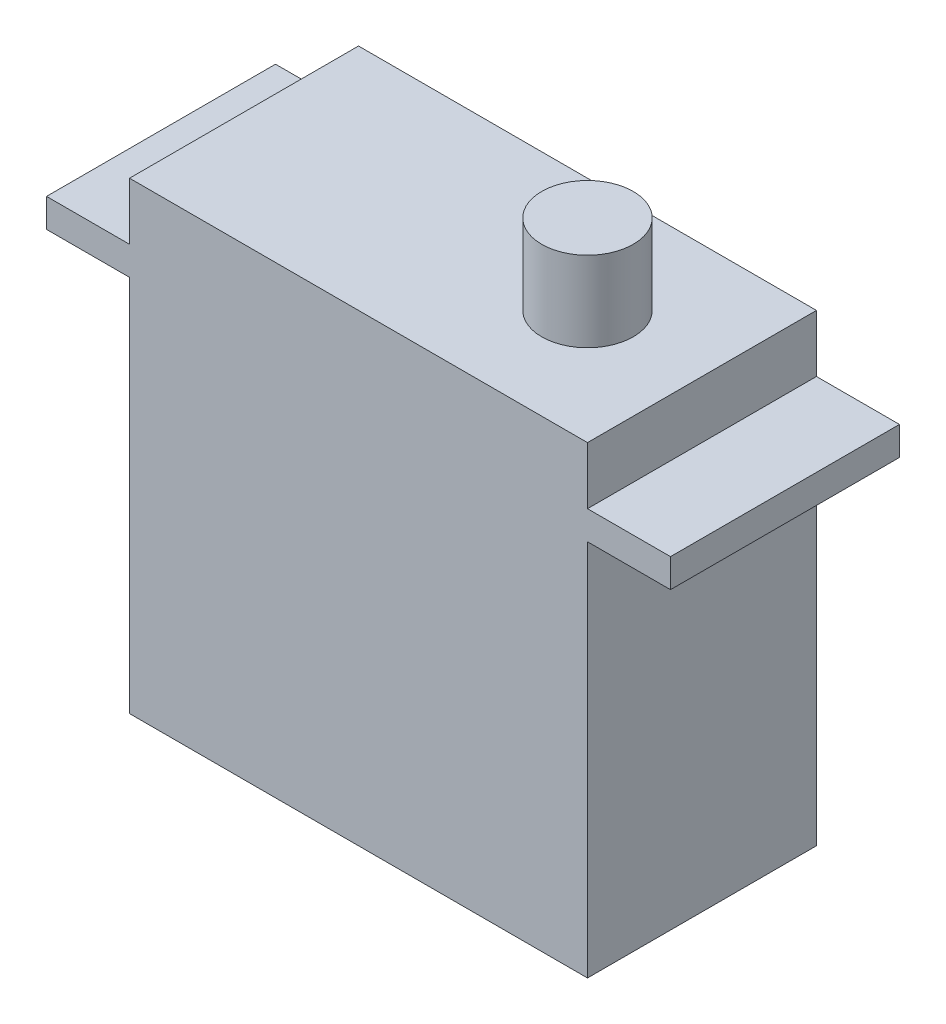
from build123d import *

# Parameters (mm, degrees)
SKETCH1_W           = 40
SKETCH1_H           = 20
BOSS_EXTRUDE1_DEPTH = 40.5
BOSS_EXTRUDE2_START = -5
SKETCH2_W           = 7.25
SKETCH2_H           = 20
BOSS_EXTRUDE2_DEPTH = 2.5
SKETCH3_R           = 10
BOSS_EXTRUDE3_DEPTH = 7
SKETCH4_R           = 10
SKETCH4_R_2         = 4
CUT_EXTRUDE1_DEPTH  = 7


with BuildPart() as part:
    # Sketch1 → Boss-Extrude1 (new body)
    with BuildSketch(Plane(origin=(0, 0, 0), x_dir=(1, 0, 0), z_dir=(0, 1, 0))):
        with Locations((-20, 10)):
            Rectangle(SKETCH1_W, SKETCH1_H)
    extrude(amount=BOSS_EXTRUDE1_DEPTH)

    # Sketch2 → Boss-Extrude2 (add)
    with BuildSketch(Plane(origin=(0, 40.5, 0), x_dir=(1, 0, 0), z_dir=(0, 1, 0)).offset(BOSS_EXTRUDE2_START)):
        with Locations((-43.625, 10)):
            Rectangle(SKETCH2_W, SKETCH2_H)
        with Locations((3.625, 10)):
            Rectangle(SKETCH2_W, SKETCH2_H)
    extrude(amount=-BOSS_EXTRUDE2_DEPTH)

    # Sketch3 → Boss-Extrude3 (add)
    with BuildSketch(Plane(origin=(0, 40.5, 0), x_dir=(1, 0, 0), z_dir=(0, 1, 0))):
        with Locations((-10, 10)):
            Circle(SKETCH3_R)
    extrude(amount=BOSS_EXTRUDE3_DEPTH)

    # Sketch4 → Cut-Extrude1 (cut)
    with BuildSketch(Plane(origin=(0, 47.5, 0), x_dir=(1, 0, 0), z_dir=(0, 1, 0))):
        with Locations((-10, 10)):
            Circle(SKETCH4_R)
        with Locations((-10, 10)):
            Circle(SKETCH4_R_2, mode=Mode.SUBTRACT)
    extrude(amount=-CUT_EXTRUDE1_DEPTH, mode=Mode.SUBTRACT)


solid = part.part
